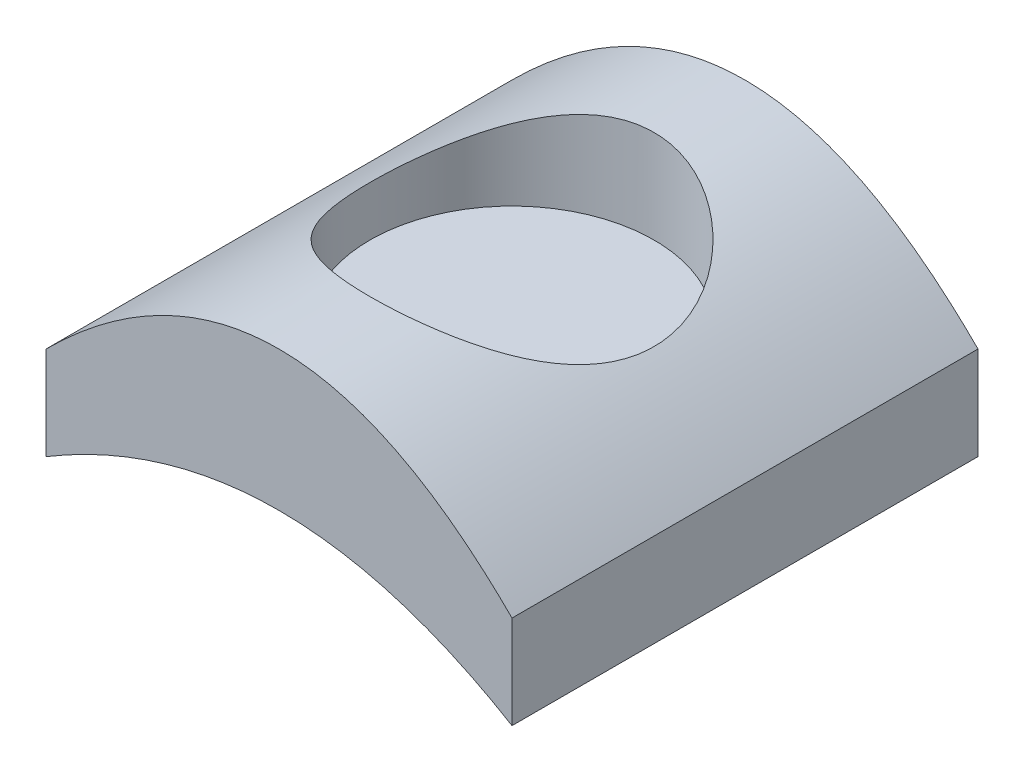
from build123d import *

# Parameters (mm, degrees)
BOSS_EXTRUDE1_DEPTH = 10
CUT_EXTRUDE1_START  = 4.5
SKETCH3_R           = 3.05
CUT_EXTRUDE1_DEPTH  = 2


with BuildPart() as part:
    # Sketch1 → Boss-Extrude1 (new body)
    with BuildSketch(Plane.XY):
        with BuildLine():
            Line((-5, 0), (-5, 2))
            add(Edge.make_bspline(
                [(-5, 2), (0, 7), (5, 2)],
                knots=[0, 0, 0, 1, 1, 1], degree=2))
            Line((5, 2), (5, 0))
            add(Edge.make_bspline(
                [(-5, 0), (0, 3), (5, 0)],
                knots=[0, 0, 0, 1, 1, 1], degree=2))
        make_face()
    extrude(amount=BOSS_EXTRUDE1_DEPTH)

    # Sketch3 → Cut-Extrude1 (cut)
    with BuildSketch(Plane(origin=(0, 0, 0), x_dir=(1, 0, 0), z_dir=(0, 1, 0)).offset(CUT_EXTRUDE1_START)):
        with Locations((0, -5)):
            Circle(SKETCH3_R)
    extrude(amount=-CUT_EXTRUDE1_DEPTH, mode=Mode.SUBTRACT)


solid = part.part
